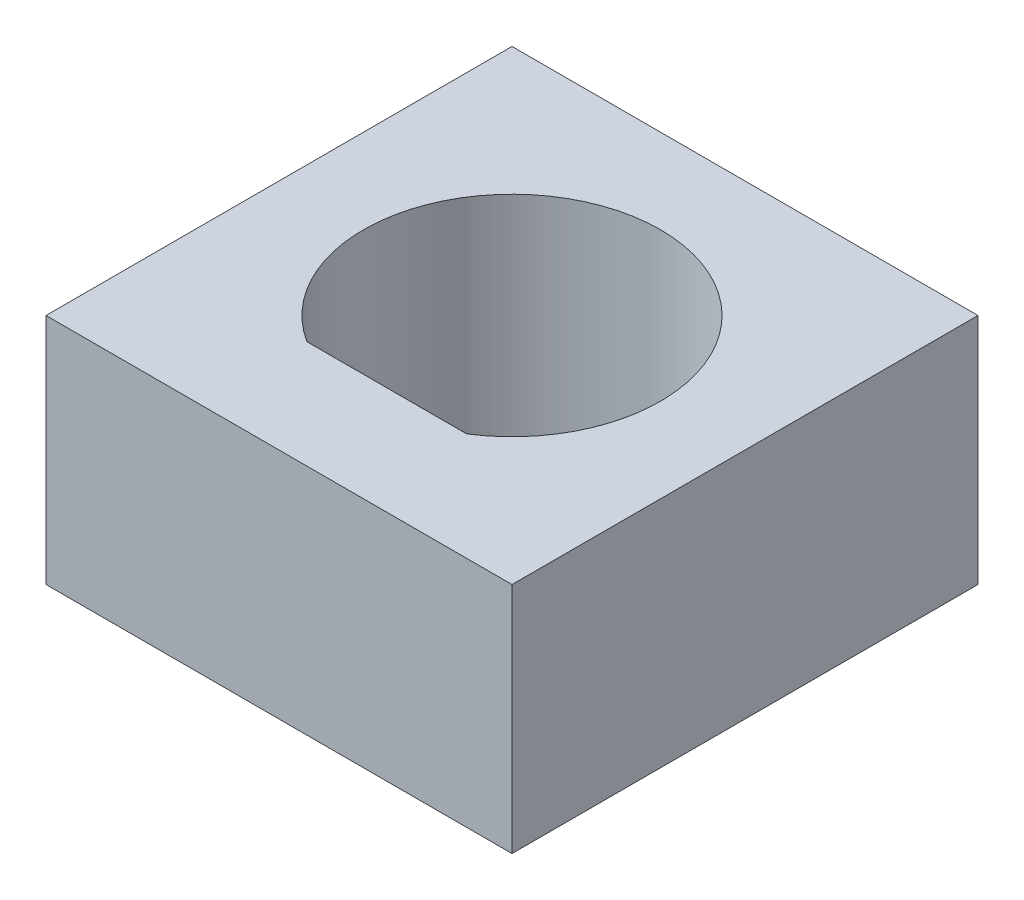
from build123d import *

# Parameters (mm, degrees)
SKETCH1_W           = 10.16
SKETCH1_H           = 10.16
BOSS_EXTRUDE1_DEPTH = 5.08


with BuildPart() as part:
    # Sketch1 → Boss-Extrude1 (new body)
    with BuildSketch(Plane(origin=(0, 0, 0), x_dir=(1, 0, 0), z_dir=(0, 1, 0))):
        Rectangle(SKETCH1_W, SKETCH1_H)
        with BuildLine():
            Line((1.741336269, -2.7305), (-1.741336269, -2.7305))
            ThreePointArc((-1.741336269, -2.7305), (0, 3.2385), (1.741336269, -2.7305))
        make_face(mode=Mode.SUBTRACT)
    extrude(amount=BOSS_EXTRUDE1_DEPTH)


solid = part.part
